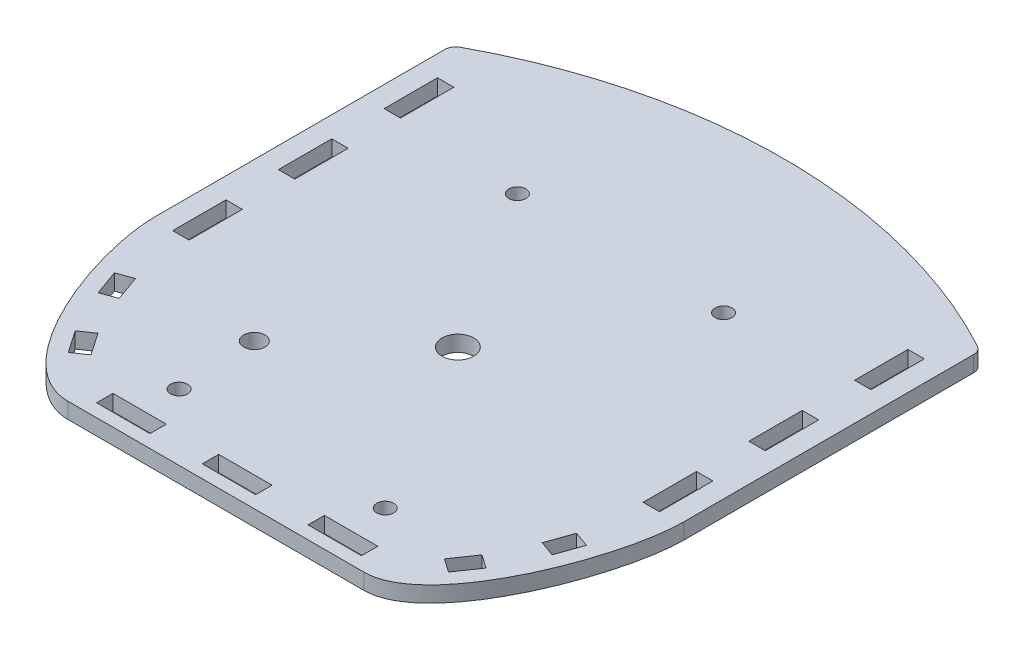
from build123d import *

# Parameters (mm, degrees)
CROQUIS1_W              = 61
CROQUIS1_H              = 100
SALIENTE_EXTRUIR1_DEPTH = 3
SALIENTE_EXTRUIR4_DEPTH = 3
CROQUIS19_W             = 61
CROQUIS19_H             = 5.5
CORTAR_EXTRUIR11_DEPTH  = 10
CORTAR_EXTRUIR7_DEPTH   = 4
REDONDEO3_R             = 2
CROQUIS15_R             = 1.6
CORTAR_EXTRUIR8_DEPTH   = 4.0000001
CROQUIS16_R             = 3
CORTAR_EXTRUIR9_DEPTH   = 4.0000001
CROQUIS17_W             = 3.1
CROQUIS17_H             = 10.1
CORTAR_EXTRUIR10_DEPTH  = 10
CORTAR_EXTRUIR13_DEPTH  = 4.0000001
CROQUIS20_W             = 10.1
CROQUIS20_H             = 3.1
CORTAR_EXTRUIR12_DEPTH  = 10
CROQUIS22_R             = 2
CORTAR_EXTRUIR14_DEPTH  = 10


with BuildPart() as part:
    # Croquis1 → Saliente-Extruir1 (new body)
    with BuildSketch(Plane(origin=(0, 0, 0), x_dir=(1, 0, 0), z_dir=(0, 1, 0))):
        with Locations((0, -18)):
            Rectangle(CROQUIS1_W, CROQUIS1_H)
    extrude(amount=SALIENTE_EXTRUIR1_DEPTH)

    # Croquis7 → Saliente-Extruir4 (add, through all)
    with BuildSketch(Plane(origin=(0, 3, 0), x_dir=(1, 0, 0), z_dir=(0, 1, 0))):
        with BuildLine():
            Line((-50, -62.5), (-50, 32))
            ThreePointArc((-50, 32), (0, 44.950013881), (50, 32))
            Line((50, 32), (50, -62.5))
            Line((50, -62.5), (-50, -62.5))
        make_face()
    extrude(amount=-SALIENTE_EXTRUIR4_DEPTH)

    # Croquis19 → Cortar-Extruir11 (cut)
    with BuildSketch(Plane(origin=(0, 3, 0), x_dir=(1, 0, 0), z_dir=(0, 1, 0))):
        with Locations((0, -65.25)):
            Rectangle(CROQUIS19_W, CROQUIS19_H)
    extrude(amount=-CORTAR_EXTRUIR11_DEPTH, mode=Mode.SUBTRACT)

    # Croquis14 → Cortar-Extruir7 (cut, through all)
    with BuildSketch(Plane(origin=(0, 3, 0), x_dir=(1, 0, 0), z_dir=(0, 1, 0))):
        with BuildLine():
            Line((-50, -24), (-50, -62.5))
            Line((-50, -62.5), (-28, -62.5))
            add(Edge.make_bspline(
                [(-50, -24), (-50, -36), (-40, -62.5), (-28, -62.5)],
                knots=[0, 0, 0, 0, 1, 1, 1, 1], degree=3))
        make_face()
    cortar_extruir7 = extrude(amount=-CORTAR_EXTRUIR7_DEPTH, mode=Mode.SUBTRACT)

    # Redondeo3
    redondeo3_edges = [part.edges().sort_by_distance(p)[0] for p in [
        (-50, 1.5, -32),
        (50, 1.5, -32),
    ]]
    fillet(redondeo3_edges, radius=REDONDEO3_R)

    # Croquis15 → Cortar-Extruir8 (cut, through all)
    with BuildSketch(Plane(origin=(0, 3, 0), x_dir=(1, 0, 0), z_dir=(0, 1, 0))):
        with Locations((-19.5, 14)):
            Circle(CROQUIS15_R)
        with Locations((19.5, 14)):
            Circle(CROQUIS15_R)
        with Locations((-19.5, -50)):
            Circle(CROQUIS15_R)
        with Locations((19.5, -50)):
            Circle(CROQUIS15_R)
    extrude(amount=-CORTAR_EXTRUIR8_DEPTH, mode=Mode.SUBTRACT)

    # Croquis16 → Cortar-Extruir9 (cut, through all)
    with BuildSketch(Plane(origin=(0, 3, 0), x_dir=(1, 0, 0), z_dir=(0, 1, 0))):
        with Locations((0, -16.75)):
            Circle(CROQUIS16_R)
    extrude(amount=-CORTAR_EXTRUIR9_DEPTH, mode=Mode.SUBTRACT)

    # Croquis17 → Cortar-Extruir10 (cut)
    with BuildSketch(Plane(origin=(0, 3, 0), x_dir=(1, 0, 0), z_dir=(0, 1, 0))):
        with Locations((-44.5, 20.395080133)):
            Rectangle(CROQUIS17_W, CROQUIS17_H)
        with Locations((-44.5, 0.395080133)):
            Rectangle(CROQUIS17_W, CROQUIS17_H)
        with Locations((-44.5, -19.604919867)):
            Rectangle(CROQUIS17_W, CROQUIS17_H)
    cortar_extruir10 = extrude(amount=-CORTAR_EXTRUIR10_DEPTH, mode=Mode.SUBTRACT)

    # Croquis21 → Cortar-Extruir13 (cut, through all)
    with BuildSketch(Plane(origin=(0, 3, 0), x_dir=(1, 0, 0), z_dir=(0, 1, 0))):
        Polygon((-44.645093952, -37.058907452), (-42.934664747, -41.863533549), (-40.014205747, -40.823860895), (-41.724634952, -36.019234798), align=None)
        Polygon((-38.866197007, -50.280851683), (-35.970669214, -54.479175015), (-33.418747189, -52.719148317), (-36.314274981, -48.520824985), align=None)
    cortar_extruir13 = extrude(amount=-CORTAR_EXTRUIR13_DEPTH, mode=Mode.SUBTRACT)

    # Simetría1: Cortar-Extruir7, Cortar-Extruir10, Cortar-Extruir13 across plane
    add(cortar_extruir7.mirror(Plane(origin=(0, 0, 0), x_dir=(0, 0, 1), z_dir=(1, 0, 0))), mode=Mode.SUBTRACT)
    add(cortar_extruir10.mirror(Plane(origin=(0, 0, 0), x_dir=(0, 0, 1), z_dir=(1, 0, 0))), mode=Mode.SUBTRACT)
    add(cortar_extruir13.mirror(Plane(origin=(0, 0, 0), x_dir=(0, 0, 1), z_dir=(1, 0, 0))), mode=Mode.SUBTRACT)

    # Croquis20 → Cortar-Extruir12 (cut)
    with BuildSketch(Plane(origin=(0, 3, 0), x_dir=(1, 0, 0), z_dir=(0, 1, 0))):
        with Locations((0, -58.5)):
            Rectangle(CROQUIS20_W, CROQUIS20_H)
        with Locations((20, -58.5)):
            Rectangle(CROQUIS20_W, CROQUIS20_H)
        with Locations((-20, -58.5)):
            Rectangle(CROQUIS20_W, CROQUIS20_H)
    extrude(amount=-CORTAR_EXTRUIR12_DEPTH, mode=Mode.SUBTRACT)

    # Croquis22 → Cortar-Extruir14 (cut)
    with BuildSketch(Plane(origin=(0, 3, 0), x_dir=(1, 0, 0), z_dir=(0, 1, 0))):
        with Locations((-20.25, -35)):
            Circle(CROQUIS22_R)
    extrude(amount=-CORTAR_EXTRUIR14_DEPTH, mode=Mode.SUBTRACT)


solid = part.part
